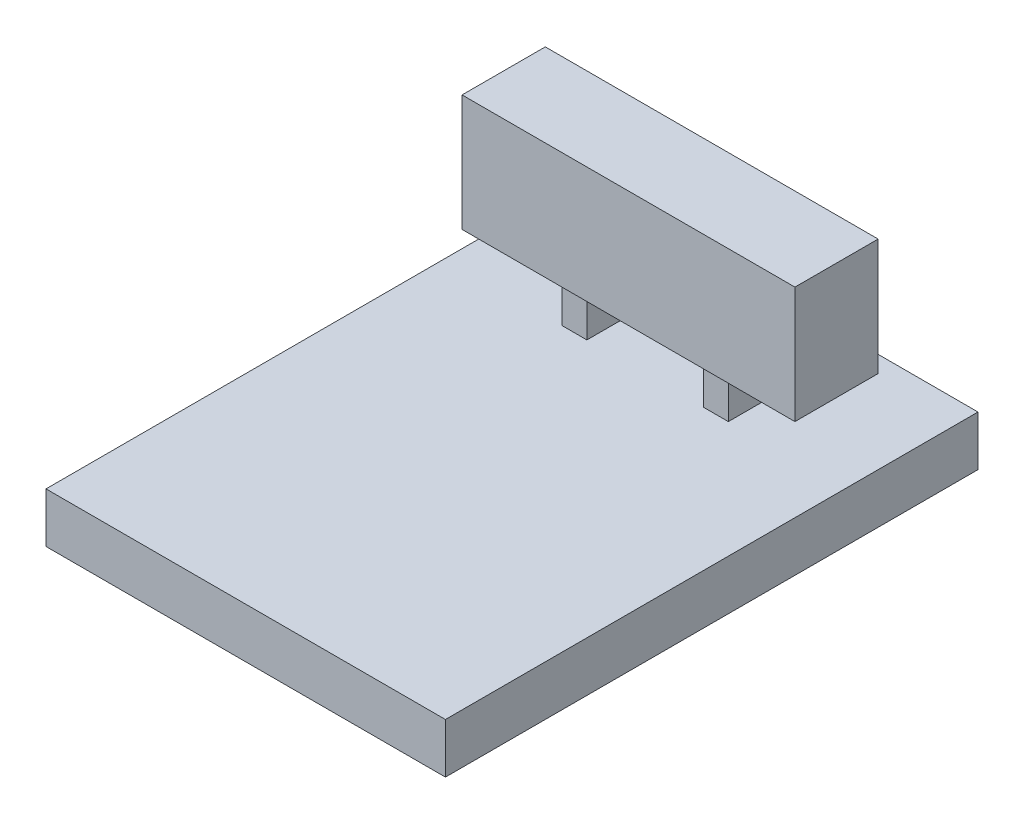
from build123d import *

# Parameters (mm, degrees)
SKETCH1_W           = 24
SKETCH1_H           = 32
BOSS_EXTRUDE1_DEPTH = 3
SKETCH2_W           = 1.5
SKETCH2_H           = 3
BOSS_EXTRUDE3_DEPTH = 3
SKETCH3_W           = 20
SKETCH3_H           = 5
BOSS_EXTRUDE4_DEPTH = 7


with BuildPart() as part:
    # Sketch1 → Boss-Extrude1 (new body)
    with BuildSketch(Plane(origin=(0, 0, 0), x_dir=(1, 0, 0), z_dir=(0, 1, 0))):
        with Locations((-10.330434783, 1.634782609)):
            Rectangle(SKETCH1_W, SKETCH1_H)
    extrude(amount=BOSS_EXTRUDE1_DEPTH)

    # Sketch2 → Boss-Extrude3 (add)
    with BuildSketch(Plane(origin=(0, 3, 0), x_dir=(1, 0, 0), z_dir=(0, 1, 0))):
        with Locations((-14.580434783, 11.134782609)):
            Rectangle(SKETCH2_W, SKETCH2_H)
        with Locations((-6.080434783, 11.134782609)):
            Rectangle(SKETCH2_W, SKETCH2_H)
    extrude(amount=BOSS_EXTRUDE3_DEPTH)

    # Sketch3 → Boss-Extrude4 (add)
    with BuildSketch(Plane(origin=(0, 6, 0), x_dir=(1, 0, 0), z_dir=(0, 1, 0))):
        with Locations((-10.330434783, 11.134782609)):
            Rectangle(SKETCH3_W, SKETCH3_H)
    extrude(amount=BOSS_EXTRUDE4_DEPTH)


solid = part.part
